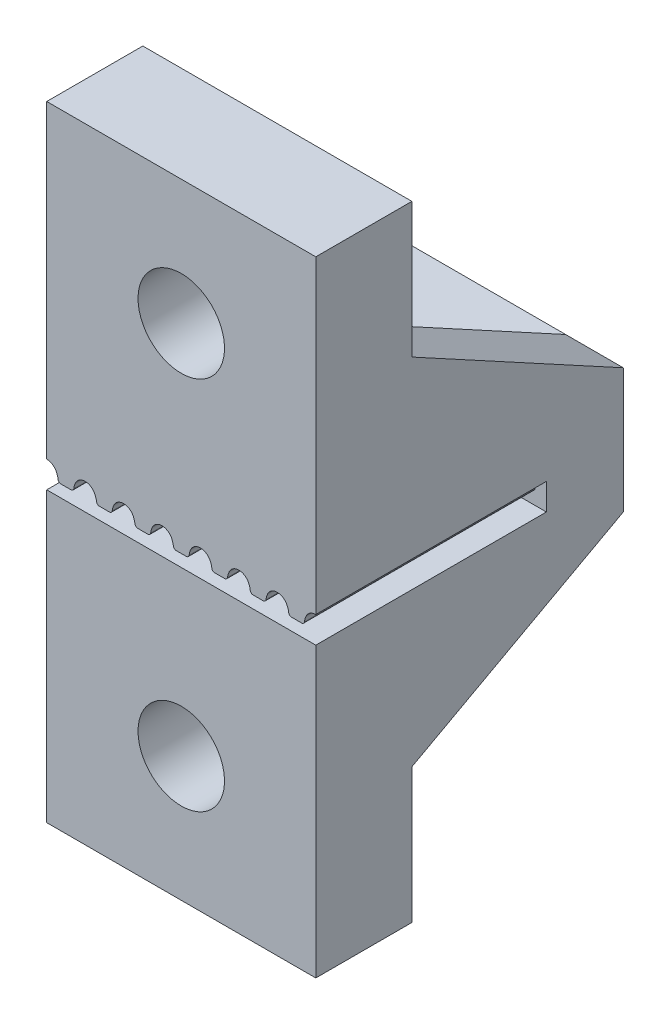
from build123d import *

# Parameters (mm, degrees)
SKETCH3_W           = 14
SKETCH3_H           = 6.5
BOSS_EXTRUDE2_DEPTH = 16
CUT_EXTRUDE1_START  = 4
CUT_EXTRUDE1_DEPTH  = 19
LPATTERN2_COUNT     = 7
LPATTERN2_PITCH     = 2
SKETCH4_W           = 14
SKETCH4_H           = 13
SKETCH4_R           = 2.25
BOSS_EXTRUDE3_DEPTH = 5
BOSS_EXTRUDE4_DEPTH = 3
BOSS_EXTRUDE5_START = -11
BOSS_EXTRUDE5_DEPTH = 3
CUT_EXTRUDE2_START  = -0.1
SKETCH5_R           = 4.5
CUT_EXTRUDE2_DEPTH  = 10.1


with BuildPart() as part:
    # Sketch3 → Boss-Extrude2 (new body)
    with BuildSketch(Plane.XY):
        with Locations((7, 1.25)):
            Rectangle(SKETCH3_W, SKETCH3_H)
    extrude(amount=BOSS_EXTRUDE2_DEPTH)

    # Sketch1 → Cut-Extrude1 (cut)
    with BuildSketch(Plane.XY.offset(CUT_EXTRUDE1_START)):
        with BuildLine():
            Line((0.740175425, 0.63), (1.259824575, 0.63))
            ThreePointArc((1.259824575, 0.63), (1.358731646, 0.667228588), (1.408543109, 0.760434783))
            ThreePointArc((1.408543109, 0.760434783), (1.442388286, 0.918062154), (1.501123596, 1.068202247))
            ThreePointArc((1.501123596, 1.068202247), (1.705850588, 1.295639059), (2, 1.38))
            Line((2, 1.38), (2, 0))
            Line((2, 0), (0, 0))
            Line((0, 0), (0, 1.38))
            ThreePointArc((0, 1.38), (0.294149412, 1.295639059), (0.498876404, 1.068202247))
            ThreePointArc((0.498876404, 1.068202247), (0.557611714, 0.918062154), (0.591456891, 0.760434783))
            ThreePointArc((0.591456891, 0.760434783), (0.641268354, 0.667228588), (0.740175425, 0.63))
        make_face()
    cut_extrude1 = extrude(amount=CUT_EXTRUDE1_DEPTH, mode=Mode.SUBTRACT)

    # LPattern2: Cut-Extrude1 ×7
    with Locations(*[(i * LPATTERN2_PITCH, 0, 0) for i in range(1, LPATTERN2_COUNT)]):
        add(cut_extrude1, mode=Mode.SUBTRACT)

    # Sketch4 → Boss-Extrude3 (add)
    # profile 1 of 2: a face of its own
    with BuildSketch(Plane(origin=(0, 4.5, 16), x_dir=(-1, 0, 0), z_dir=(0, 0, -1))):
        with Locations((-7, -13)):
            Rectangle(SKETCH4_W, SKETCH4_H)
        with Locations((-7, -13)):
            Circle(SKETCH4_R, mode=Mode.SUBTRACT)
    # profile 2 of 2: a face of its own
    with BuildSketch(Plane(origin=(0, 4.5, 16), x_dir=(-1, 0, 0), z_dir=(0, 0, -1))):
        with Locations((-7, 6.5)):
            Rectangle(SKETCH4_W, SKETCH4_H)
        with Locations((-7, 6.5)):
            Circle(SKETCH4_R, mode=Mode.SUBTRACT)
    extrude(amount=BOSS_EXTRUDE3_DEPTH)

    # Sketch7 → Boss-Extrude4 (add)
    with BuildSketch(Plane.ZY):
        Polygon((0, -2), (11, -7.982839213), (11, -2), align=None)
    boss_extrude4 = extrude(amount=-BOSS_EXTRUDE4_DEPTH)

    # Sketch7_2 → Boss-Extrude5 (add)
    with BuildSketch(Plane.ZY.offset(BOSS_EXTRUDE5_START)):
        Polygon((0, -2), (11, -7.982839213), (11, -2), align=None)
    boss_extrude5 = extrude(amount=-BOSS_EXTRUDE5_DEPTH)

    # Sketch5 → Cut-Extrude2 (cut)
    with BuildSketch(Plane(origin=(0, 0, 11), x_dir=(-1, 0, 0), z_dir=(0, 0, -1)).offset(CUT_EXTRUDE2_START)):
        with Locations((-7, 11)):
            Circle(SKETCH5_R)
        with Locations((-7, -8.5)):
            Circle(SKETCH5_R)
    cut_extrude2 = extrude(amount=CUT_EXTRUDE2_DEPTH, mode=Mode.SUBTRACT)

    # Mirror1: Boss-Extrude4, Boss-Extrude5, Cut-Extrude2 across plane
    add(boss_extrude4.mirror(Plane.ZX.offset(1.25)))
    add(boss_extrude5.mirror(Plane.ZX.offset(1.25)))
    add(cut_extrude2.mirror(Plane.ZX.offset(1.25)), mode=Mode.SUBTRACT)


solid = part.part
